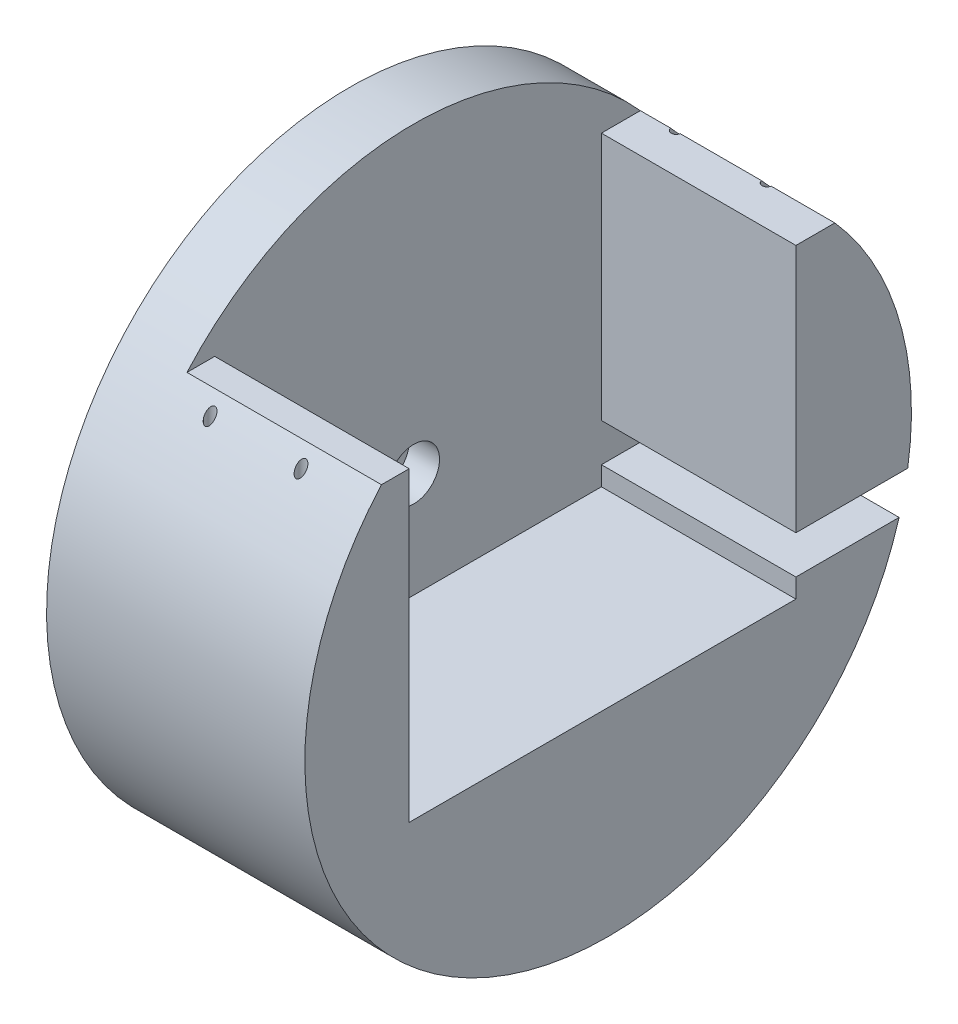
from build123d import *

# Parameters (mm, degrees)
SKETCH1_R           = 31.6865
BOSS_EXTRUDE1_DEPTH = 26.9875
CUT_EXTRUDE1_DEPTH  = 20.32
SKETCH5_R           = 0.508
CUT_EXTRUDE2_DEPTH  = 12.7
SKETCH6_R           = 0.508
CUT_EXTRUDE3_DEPTH  = 3.556
SKETCH7_R           = 2.69875
BOSS_EXTRUDE2_DEPTH = 3.175
SKETCH11_R          = 2.69875
CUT_EXTRUDE6_DEPTH  = 3.175
SKETCH12_R          = 1.651
CUT_EXTRUDE7_DEPTH  = 9.017


with BuildPart() as part:
    # Sketch1 → Boss-Extrude1 (new body)
    with BuildSketch(Plane(origin=(0, 0, 0), x_dir=(0, 0, -1), z_dir=(1, 0, 0))):
        Circle(SKETCH1_R)
    extrude(amount=BOSS_EXTRUDE1_DEPTH)

    # Sketch3 → Cut-Extrude1 (cut)
    with BuildSketch(Plane(origin=(26.9875, 0, 0), x_dir=(0, 0, -1), z_dir=(1, 0, 0))):
        with BuildLine():
            Line((19.614864522, -8.95), (30.396246187, -8.95))
            ThreePointArc((30.396246187, -8.95), (30.911627748, -6.964592752), (31.297472458, -4.95))
            Line((31.297472458, -4.95), (19.614864522, -4.95))
            Line((19.614864522, -4.95), (19.614864522, 21.05))
            Line((19.614864522, 21.05), (23.683998443, 21.05))
            ThreePointArc((23.683998443, 21.05), (0, 31.6865), (-23.683998443, 21.05))
            Line((-23.683998443, 21.05), (-20.785135478, 21.05))
            Line((-20.785135478, 21.05), (-20.785135478, -10.95))
            Line((-20.785135478, -10.95), (19.614864522, -10.95))
            Line((19.614864522, -10.95), (19.614864522, -8.95))
        make_face()
    extrude(amount=-CUT_EXTRUDE1_DEPTH, mode=Mode.SUBTRACT)

    # Sketch5 → Cut-Extrude2 (cut)
    with BuildSketch(Plane(origin=(0, 21.05, 0), x_dir=(1, 0, 0), z_dir=(0, 1, 0))):
        with Locations((10.33, -24.932573059)):
            Circle(SKETCH5_R)
        with Locations((19.83, -24.932573059)):
            Circle(SKETCH5_R)
        with Locations((10.33, 23.762302103)):
            Circle(SKETCH5_R)
        with Locations((19.83, 23.762302103)):
            Circle(SKETCH5_R)
    extrude(amount=-CUT_EXTRUDE2_DEPTH, mode=Mode.SUBTRACT)

    # Sketch6 → Cut-Extrude3 (cut)
    with BuildSketch(Plane.ZY):
        with Locations((-1.539927539, 19.940627452)):
            Circle(SKETCH6_R)
    extrude(amount=-CUT_EXTRUDE3_DEPTH, mode=Mode.SUBTRACT)

    # Sketch7 → Boss-Extrude2 (add)
    with BuildSketch(Plane(origin=(6.6675, 0, 0), x_dir=(0, 0, -1), z_dir=(1, 0, 0))):
        Circle(SKETCH7_R)
    extrude(amount=-BOSS_EXTRUDE2_DEPTH)

    # Sketch11 → Cut-Extrude6 (cut)
    with BuildSketch(Plane(origin=(6.6675, 0, 0), x_dir=(0, 0, -1), z_dir=(1, 0, 0))):
        Circle(SKETCH11_R)
    extrude(amount=-CUT_EXTRUDE6_DEPTH, mode=Mode.SUBTRACT)

    # Sketch12 → Cut-Extrude7 (cut)
    with BuildSketch(Plane.ZY):
        Circle(SKETCH12_R)
    extrude(amount=-CUT_EXTRUDE7_DEPTH, mode=Mode.SUBTRACT)


solid = part.part
